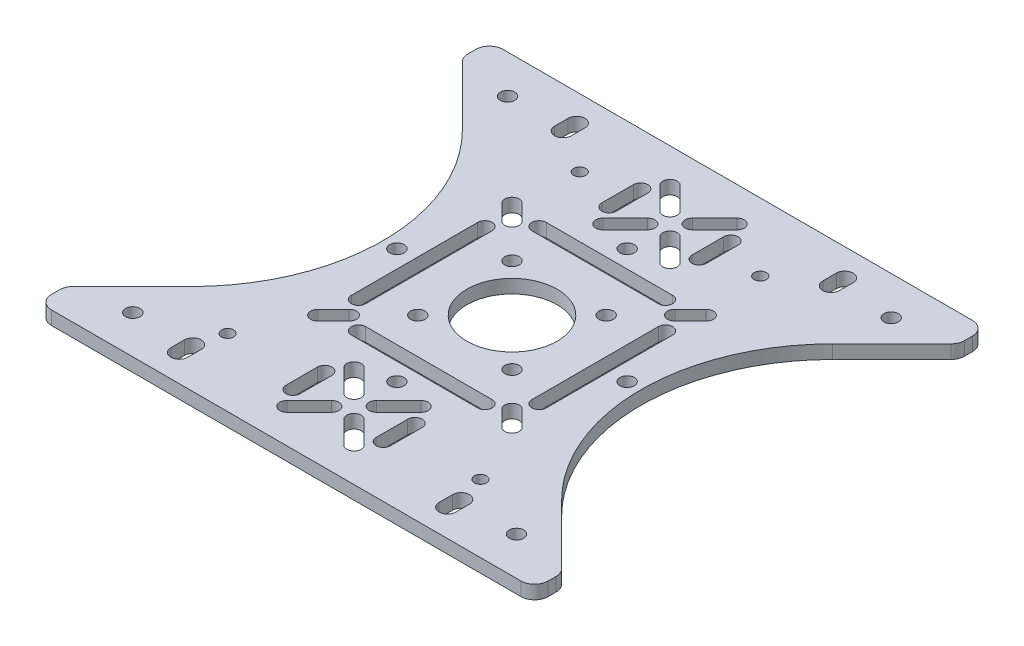
from build123d import *

# Parameters (mm, degrees)
SKETCH1_W           = 110
SKETCH1_H           = 100
SKETCH1_R           = 1.6
SKETCH1_R_2         = 1.35
BOSS_EXTRUDE1_DEPTH = 3
SKETCH2_R           = 10
SKETCH2_R_2         = 1.6
CUT_EXTRUDE1_DEPTH  = 4
CUT_EXTRUDE2_DEPTH  = 4
FILLET2_R           = 3
CUT_EXTRUDE_1_DEPTH = 4


with BuildPart() as part:
    # Sketch1 → Boss-Extrude1 (new body)
    with BuildSketch(Plane(origin=(0, 0, 0), x_dir=(1, 0, 0), z_dir=(0, 1, 0))):
        Rectangle(SKETCH1_W, SKETCH1_H)
        with Locations((42.5, 41.5)):
            Circle(SKETCH1_R, mode=Mode.SUBTRACT)
        with Locations((20, 35)):
            Circle(SKETCH1_R_2, mode=Mode.SUBTRACT)
        with Locations((-20, 35)):
            Circle(SKETCH1_R_2, mode=Mode.SUBTRACT)
        with Locations((28, -35)):
            Circle(SKETCH1_R_2, mode=Mode.SUBTRACT)
        with Locations((-28, -35)):
            Circle(SKETCH1_R_2, mode=Mode.SUBTRACT)
        with Locations((-42.5, 41.5)):
            Circle(SKETCH1_R, mode=Mode.SUBTRACT)
        with Locations((42.5, -41.5)):
            Circle(SKETCH1_R, mode=Mode.SUBTRACT)
        with Locations((-42.5, -41.5)):
            Circle(SKETCH1_R, mode=Mode.SUBTRACT)
    extrude(amount=BOSS_EXTRUDE1_DEPTH)

    # Sketch2 → Cut-Extrude1 (cut, through all)
    with BuildSketch(Plane(origin=(0, 3, 0), x_dir=(1, 0, 0), z_dir=(0, 1, 0))):
        Circle(SKETCH2_R)
        with Locations((-10.429825023, -10.429825023)):
            Circle(SKETCH2_R_2)
        with Locations((10.429825023, -10.429825023)):
            Circle(SKETCH2_R_2)
        with Locations((-10.429825023, 10.429825023)):
            Circle(SKETCH2_R_2)
        with Locations((10.429825023, 10.429825023)):
            Circle(SKETCH2_R_2)
        with Locations((25.5, 0)):
            Circle(SKETCH2_R_2)
        with Locations((0, -25.5)):
            Circle(SKETCH2_R_2)
        with Locations((-25.5, 0)):
            Circle(SKETCH2_R_2)
        with Locations((0, 25.5)):
            Circle(SKETCH2_R_2)
        with BuildLine():
            Line((-14, 21.6), (14, 21.6))
            ThreePointArc((14, 21.6), (15.6, 20), (14, 18.4))
            Line((14, 18.4), (-14, 18.4))
            ThreePointArc((-14, 18.4), (-15.6, 20), (-14, 21.6))
        make_face()
        with BuildLine():
            Line((-14, -21.6), (14, -21.6))
            ThreePointArc((14, -21.6), (15.6, -20), (14, -18.4))
            Line((14, -18.4), (-14, -18.4))
            ThreePointArc((-14, -18.4), (-15.6, -20), (-14, -21.6))
        make_face()
        with BuildLine():
            Line((21.6, 14), (21.6, -14))
            ThreePointArc((21.6, -14), (20, -15.6), (18.4, -14))
            Line((18.4, -14), (18.4, 14))
            ThreePointArc((18.4, 14), (20, 15.6), (21.6, 14))
        make_face()
        with BuildLine():
            Line((-21.6, 14), (-21.6, -14))
            ThreePointArc((-21.6, -14), (-20, -15.6), (-18.4, -14))
            Line((-18.4, -14), (-18.4, 14))
            ThreePointArc((-18.4, 14), (-20, 15.6), (-21.6, 14))
        make_face()
        with BuildLine():
            Line((-20.36862915, 22.63137085), (-16.89985207, 19.16259377))
            ThreePointArc((-16.89985207, 19.16259377), (-16.89985207, 16.89985207), (-19.16259377, 16.89985207))
            Line((-19.16259377, 16.89985207), (-22.63137085, 20.36862915))
            ThreePointArc((-22.63137085, 20.36862915), (-22.63137085, 22.63137085), (-20.36862915, 22.63137085))
        make_face()
        with BuildLine():
            Line((20.36862915, 22.63137085), (16.89985207, 19.16259377))
            ThreePointArc((16.89985207, 19.16259377), (16.89985207, 16.89985207), (19.16259377, 16.89985207))
            Line((19.16259377, 16.89985207), (22.63137085, 20.36862915))
            ThreePointArc((22.63137085, 20.36862915), (22.63137085, 22.63137085), (20.36862915, 22.63137085))
        make_face()
        with BuildLine():
            Line((20.36862915, -22.63137085), (16.89985207, -19.16259377))
            ThreePointArc((16.89985207, -19.16259377), (16.89985207, -16.89985207), (19.16259377, -16.89985207))
            Line((19.16259377, -16.89985207), (22.63137085, -20.36862915))
            ThreePointArc((22.63137085, -20.36862915), (22.63137085, -22.63137085), (20.36862915, -22.63137085))
        make_face()
        with BuildLine():
            Line((-20.36862915, -22.63137085), (-16.89985207, -19.16259377))
            ThreePointArc((-16.89985207, -19.16259377), (-16.89985207, -16.89985207), (-19.16259377, -16.89985207))
            Line((-19.16259377, -16.89985207), (-22.63137085, -20.36862915))
            ThreePointArc((-22.63137085, -20.36862915), (-22.63137085, -22.63137085), (-20.36862915, -22.63137085))
        make_face()
    extrude(amount=-CUT_EXTRUDE1_DEPTH, mode=Mode.SUBTRACT)

    # Sketch3 → Cut-Extrude2 (cut, through all)
    with BuildSketch(Plane(origin=(0, 3, 0), x_dir=(1, 0, 0), z_dir=(0, 1, 0))):
        with BuildLine():
            Line((3.606244584, 33.656497116), (8.555992052, 28.706749647))
            ThreePointArc((8.555992052, 28.706749647), (8.555992052, 26.444007948), (6.293250353, 26.444007948))
            Line((6.293250353, 26.444007948), (1.343502884, 31.393755416))
            ThreePointArc((1.343502884, 31.393755416), (1.343502884, 33.656497116), (3.606244584, 33.656497116))
        make_face()
        with BuildLine():
            Line((-1.343502884, 31.393755416), (-6.293250353, 26.444007948))
            ThreePointArc((-6.293250353, 26.444007948), (-8.555992052, 26.444007948), (-8.555992052, 28.706749647))
            Line((-8.555992052, 28.706749647), (-3.606244584, 33.656497116))
            ThreePointArc((-3.606244584, 33.656497116), (-1.343502884, 33.656497116), (-1.343502884, 31.393755416))
        make_face()
        with BuildLine():
            Line((-3.606244584, 36.343502884), (-8.555992052, 41.293250353))
            ThreePointArc((-8.555992052, 41.293250353), (-8.555992052, 43.555992052), (-6.293250353, 43.555992052))
            Line((-6.293250353, 43.555992052), (-1.343502884, 38.606244584))
            ThreePointArc((-1.343502884, 38.606244584), (-1.343502884, 36.343502884), (-3.606244584, 36.343502884))
        make_face()
        with BuildLine():
            Line((1.343502884, 38.606244584), (6.293250353, 43.555992052))
            ThreePointArc((6.293250353, 43.555992052), (8.555992052, 43.555992052), (8.555992052, 41.293250353))
            Line((8.555992052, 41.293250353), (3.606244584, 36.343502884))
            ThreePointArc((3.606244584, 36.343502884), (1.343502884, 36.343502884), (1.343502884, 38.606244584))
        make_face()
        with BuildLine():
            Line((11.6, 38.5), (11.6, 31.5))
            ThreePointArc((11.6, 31.5), (10, 29.9), (8.4, 31.5))
            Line((8.4, 31.5), (8.4, 38.5))
            ThreePointArc((8.4, 38.5), (10, 40.1), (11.6, 38.5))
        make_face()
        with BuildLine():
            Line((-11.6, 38.5), (-11.6, 31.5))
            ThreePointArc((-11.6, 31.5), (-10, 29.9), (-8.4, 31.5))
            Line((-8.4, 31.5), (-8.4, 38.5))
            ThreePointArc((-8.4, 38.5), (-10, 40.1), (-11.6, 38.5))
        make_face()
        with BuildLine():
            Line((3.606244584, -33.656497116), (8.555992052, -28.706749647))
            ThreePointArc((8.555992052, -28.706749647), (8.555992052, -26.444007948), (6.293250353, -26.444007948))
            Line((6.293250353, -26.444007948), (1.343502884, -31.393755416))
            ThreePointArc((1.343502884, -31.393755416), (1.343502884, -33.656497116), (3.606244584, -33.656497116))
        make_face()
        with BuildLine():
            Line((11.6, -38.5), (11.6, -31.5))
            ThreePointArc((11.6, -31.5), (10, -29.9), (8.4, -31.5))
            Line((8.4, -31.5), (8.4, -38.5))
            ThreePointArc((8.4, -38.5), (10, -40.1), (11.6, -38.5))
        make_face()
        with BuildLine():
            Line((1.343502884, -38.606244584), (6.293250353, -43.555992052))
            ThreePointArc((6.293250353, -43.555992052), (8.555992052, -43.555992052), (8.555992052, -41.293250353))
            Line((8.555992052, -41.293250353), (3.606244584, -36.343502884))
            ThreePointArc((3.606244584, -36.343502884), (1.343502884, -36.343502884), (1.343502884, -38.606244584))
        make_face()
        with BuildLine():
            Line((-1.343502884, -31.393755416), (-6.293250353, -26.444007948))
            ThreePointArc((-6.293250353, -26.444007948), (-8.555992052, -26.444007948), (-8.555992052, -28.706749647))
            Line((-8.555992052, -28.706749647), (-3.606244584, -33.656497116))
            ThreePointArc((-3.606244584, -33.656497116), (-1.343502884, -33.656497116), (-1.343502884, -31.393755416))
        make_face()
        with BuildLine():
            Line((-11.6, -38.5), (-11.6, -31.5))
            ThreePointArc((-11.6, -31.5), (-10, -29.9), (-8.4, -31.5))
            Line((-8.4, -31.5), (-8.4, -38.5))
            ThreePointArc((-8.4, -38.5), (-10, -40.1), (-11.6, -38.5))
        make_face()
        with BuildLine():
            Line((-3.606244584, -36.343502884), (-8.555992052, -41.293250353))
            ThreePointArc((-8.555992052, -41.293250353), (-8.555992052, -43.555992052), (-6.293250353, -43.555992052))
            Line((-6.293250353, -43.555992052), (-1.343502884, -38.606244584))
            ThreePointArc((-1.343502884, -38.606244584), (-1.343502884, -36.343502884), (-3.606244584, -36.343502884))
        make_face()
        with BuildLine():
            Line((-56, 45), (-41, 30))
            ThreePointArc((-41, 30), (-28.573593129, 0), (-41, -30))
            Line((-41, -30), (-56, -45))
            Line((-56, -45), (-56, 45))
        make_face()
        with BuildLine():
            Line((56, 45), (41, 30))
            ThreePointArc((41, 30), (28.573593129, 0), (41, -30))
            Line((41, -30), (56, -45))
            Line((56, -45), (56, 45))
        make_face()
    extrude(amount=-CUT_EXTRUDE2_DEPTH, mode=Mode.SUBTRACT)

    # Fillet2
    fillet2_edges = [part.edges().sort_by_distance(p)[0] for p in [
        (-55, 1.5, 44),
        (-55, 1.5, -44),
        (55, 1.5, 44),
        (55, 1.5, -44),
        (55, 1.5, 50),
        (-55, 1.5, 50),
        (-55, 1.5, -50),
        (55, 1.5, -50),
    ]]
    fillet(fillet2_edges, radius=FILLET2_R)

    # 草图1 → 切除-拉伸1 (cut, through all)
    with BuildSketch(Plane(origin=(0, 3, 0), x_dir=(1, 0, 0), z_dir=(0, 1, 0))):
        with BuildLine():
            Line((-27.85, -41), (-27.85, -44))
            ThreePointArc((-27.85, -44), (-29.7, -45.85), (-31.55, -44))
            Line((-31.55, -44), (-31.55, -41))
            ThreePointArc((-31.55, -41), (-29.7, -39.15), (-27.85, -41))
        make_face()
        with BuildLine():
            Line((27.85, -41), (27.85, -44))
            ThreePointArc((27.85, -44), (29.7, -45.85), (31.55, -44))
            Line((31.55, -44), (31.55, -41))
            ThreePointArc((31.55, -41), (29.7, -39.15), (27.85, -41))
        make_face()
        with BuildLine():
            Line((27.85, 41), (27.85, 44))
            ThreePointArc((27.85, 44), (29.7, 45.85), (31.55, 44))
            Line((31.55, 44), (31.55, 41))
            ThreePointArc((31.55, 41), (29.7, 39.15), (27.85, 41))
        make_face()
        with BuildLine():
            Line((-27.85, 41), (-27.85, 44))
            ThreePointArc((-27.85, 44), (-29.7, 45.85), (-31.55, 44))
            Line((-31.55, 44), (-31.55, 41))
            ThreePointArc((-31.55, 41), (-29.7, 39.15), (-27.85, 41))
        make_face()
    extrude(amount=-CUT_EXTRUDE_1_DEPTH, mode=Mode.SUBTRACT)


solid = part.part
